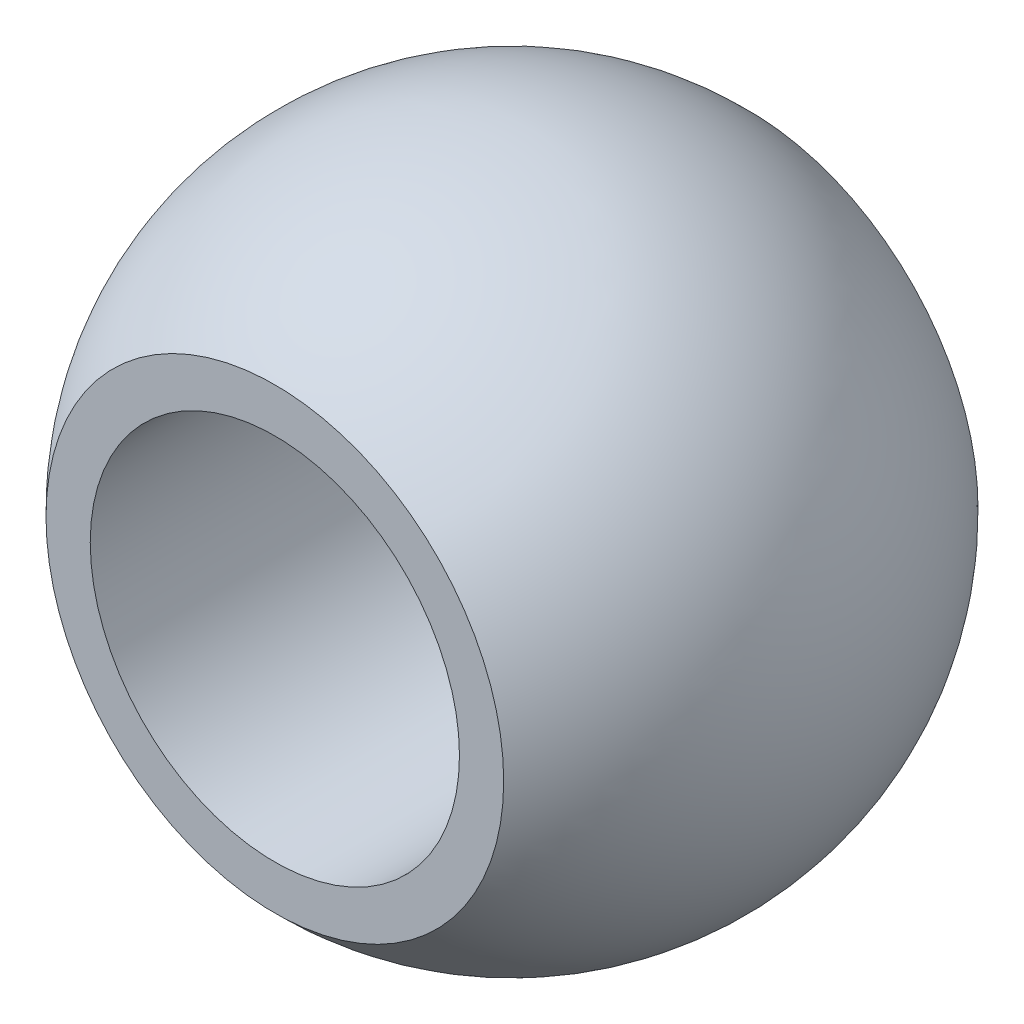
from build123d import *

# Parameters (mm, degrees)
CUT_EXTRUDE3_DEPTH      = 18.179692345
CUT_EXTRUDE3_DEPTH_BACK = 18.179692345
SKETCH4_R               = 5.55625
CUT_EXTRUDE4_DEPTH      = 18.179692345
CUT_EXTRUDE4_DEPTH_BACK = 18.179692345
SKETCH3_OUTSIDE_W       = 28.71
SKETCH3_OUTSIDE_H       = 28.71
SKETCH3_OUTSIDE_W_2     = 39.998671672
SKETCH3_OUTSIDE_H_2     = 14.2748


with BuildPart() as part:
    # Sketch2 → Revolve2 (revolve)
    with BuildSketch(Plane.XY):
        with BuildLine():
            Line((0, 9.9187), (0, -9.9187))
            ThreePointArc((0, -9.9187), (9.9187, 0), (0, 9.9187))
        make_face()
    revolve(axis=Axis((0, 12.922977109, 0), (0, -1, 0)))

    # Sketch4 → Cut-Extrude3 (cut, two sides: drawn at the far end of the back side and taken through both)
    with BuildSketch(Plane.XY.offset(-CUT_EXTRUDE3_DEPTH_BACK)):
        with Locations(Location((0, 0, 0), (0, 0, 180))):
            Circle(SKETCH4_R)
    extrude(amount=CUT_EXTRUDE3_DEPTH + CUT_EXTRUDE3_DEPTH_BACK, mode=Mode.SUBTRACT)

    # Sketch3 outside → Cut-Extrude4 (cut, two sides: drawn at the far end of the back side and taken through both)
    with BuildSketch(Plane(origin=(0, 0, 0), x_dir=(1, 0, 0), z_dir=(0, 1, 0)).offset(-CUT_EXTRUDE4_DEPTH_BACK)):
        Rectangle(SKETCH3_OUTSIDE_W, SKETCH3_OUTSIDE_H)
        Rectangle(SKETCH3_OUTSIDE_W_2, SKETCH3_OUTSIDE_H_2, mode=Mode.SUBTRACT)
    extrude(amount=CUT_EXTRUDE4_DEPTH + CUT_EXTRUDE4_DEPTH_BACK, mode=Mode.SUBTRACT)


solid = part.part
